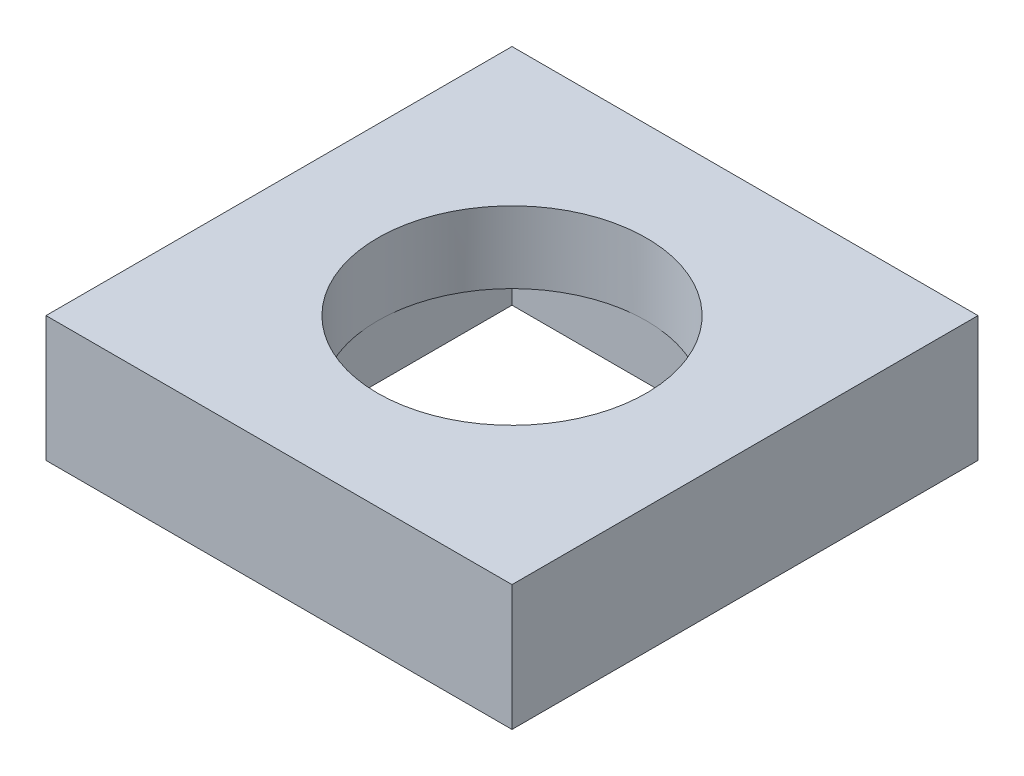
from build123d import *

# Parameters (mm, degrees)
SKETCH1_W           = 2.6
SKETCH1_H           = 2.6
SKETCH1_R           = 0.75
BOSS_EXTRUDE1_DEPTH = 0.7
SKETCH2_W           = 1.5
SKETCH2_H           = 1.5
CUT_EXTRUDE1_DEPTH  = 0.3


with BuildPart() as part:
    # Sketch1 → Boss-Extrude1 (new body)
    with BuildSketch(Plane(origin=(0, 0, 0), x_dir=(1, 0, 0), z_dir=(0, 1, 0))):
        with Locations((-0.311764706, -0.709625668)):
            Rectangle(SKETCH1_W, SKETCH1_H)
        with Locations((-0.311764706, -0.709625668)):
            Circle(SKETCH1_R, mode=Mode.SUBTRACT)
    extrude(amount=BOSS_EXTRUDE1_DEPTH)

    # Sketch2 → Cut-Extrude1 (cut)
    with BuildSketch(Plane.XZ):
        with Locations((-0.311764706, 0.709625668)):
            Rectangle(SKETCH2_W, SKETCH2_H)
    extrude(amount=-CUT_EXTRUDE1_DEPTH, mode=Mode.SUBTRACT)


solid = part.part
